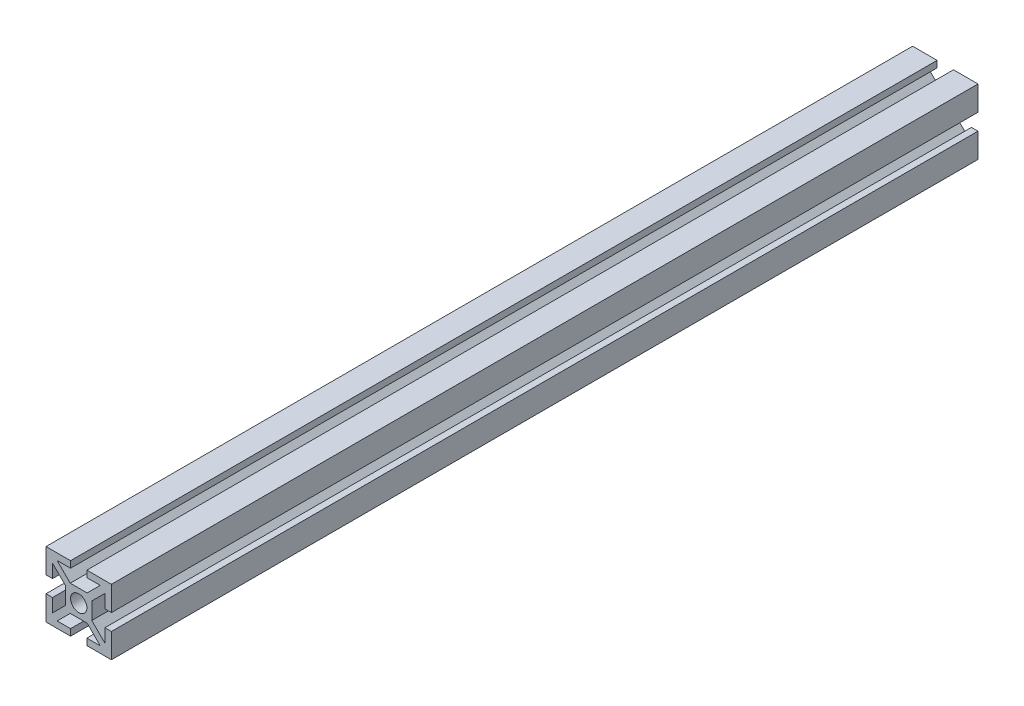
from build123d import *

# Parameters (mm, degrees)
BOSS_EXTRUDE1_DEPTH     = 132.5
CUT_EXTRUDE3_DEPTH      = 132.5
CUT_EXTRUDE3_DEPTH_BACK = 132.5
SKETCH2_R               = 2.5


with BuildPart() as part:
    # Sketch1 → Boss-Extrude1 (new, symmetric)
    with BuildSketch(Plane.XY):
        Polygon((-2.585786438, 4), (2.585786438, 4), (6.585786438, 8), (2.5, 8), (2.5, 10), (10, 10), (10, 2.5), (8, 2.5), (8, 6.585786438), (4, 2.585786438), (4, -2.585786438), (8, -6.585786438), (8, -2.5), (10, -2.5), (10, -10), (2.5, -10), (2.5, -8), (6.585786438, -8), (2.585786438, -4), (-2.585786438, -4), (-6.585786438, -8), (-2.5, -8), (-2.5, -10), (-10, -10), (-10, -2.5), (-8, -2.5), (-8, -6.585786438), (-4, -2.585786438), (-4, 2.585786438), (-8, 6.585786438), (-8, 2.5), (-10, 2.5), (-10, 10), (-2.5, 10), (-2.5, 8), (-6.585786438, 8), align=None)
    extrude(amount=BOSS_EXTRUDE1_DEPTH, both=True)

    # Sketch2 → Cut-Extrude3 (cut, two sides: drawn at the far end of the back side and taken through both)
    with BuildSketch(Plane.XY.offset(-CUT_EXTRUDE3_DEPTH_BACK)):
        Circle(SKETCH2_R)
    extrude(amount=CUT_EXTRUDE3_DEPTH + CUT_EXTRUDE3_DEPTH_BACK, mode=Mode.SUBTRACT)


solid = part.part
